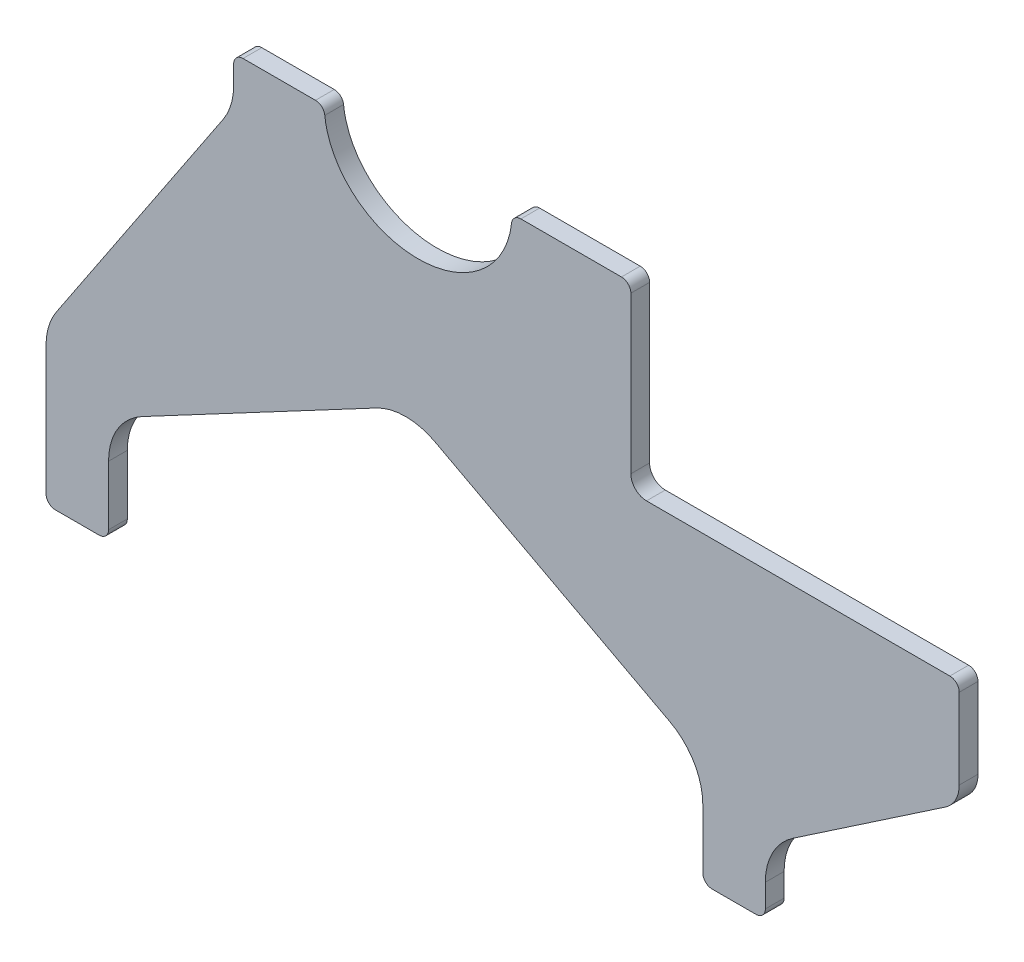
from build123d import *

# Parameters (mm, degrees)
EXTRUDE1_DEPTH = 6


with BuildPart() as part:
    # Sketch1 → Extrude1 (new body)
    with BuildSketch(Plane.XY):
        with BuildLine():
            Line((-9.389431256, -4.992449157), (-84.389431256, -44.870656531))
            ThreePointArc((-84.389431256, -44.870656531), (-92.143346014, -52.22884689), (-95, -62.529608388))
            Line((-95, -62.529608388), (-95, -81.512396008))
            ThreePointArc((-95, -81.512396008), (-95.878679656, -83.633716351), (-98, -84.512396008))
            Line((-98, -84.512396008), (-112, -84.512396008))
            ThreePointArc((-112, -84.512396008), (-114.121320344, -83.633716351), (-115, -81.512396008))
            Line((-115, -81.512396008), (-115, -40.567908762))
            ThreePointArc((-115, -40.567908762), (-114.14184053, -34.772225789), (-111.641005887, -29.473904838))
            Line((-111.641005887, -29.473904838), (-58.358994113, 50.449112822))
            ThreePointArc((-58.358994113, 50.449112822), (-55.85815947, 55.747433773), (-55, 61.543116747))
            Line((-55, 61.543116747), (-55, 67.487603992))
            ThreePointArc((-55, 67.487603992), (-54.121320344, 69.608924336), (-52, 70.487603992))
            Line((-52, 70.487603992), (-28.840084091, 70.487603992))
            ThreePointArc((-28.840084091, 70.487603992), (-26.834640517, 69.718791136), (-25.85707081, 67.806401373))
            add(Edge.make_bspline(
                [(-25.85707081, 67.806401373), (-23.204663037, 42.987603992), (4, 42.987603992), (31.204663037, 42.987603992), (33.85707081, 67.806401373)],
                knots=[3.239246064, 3.239246064, 3.239246064, 4.71238898, 4.71238898, 6.185531897, 6.185531897, 6.185531897], degree=2, weights=[1, 0.740776038, 1, 0.740776038, 1]))
            ThreePointArc((33.85707081, 67.806401373), (34.834640517, 69.718791136), (36.840084091, 70.487603992))
            Line((36.840084091, 70.487603992), (69, 70.487603992))
            ThreePointArc((69, 70.487603992), (71.121320344, 69.608924336), (72, 67.487603992))
            Line((72, 67.487603992), (72, 17.487603992))
            ThreePointArc((72, 17.487603992), (73.464466094, 13.952070086), (77, 12.487603992))
            Line((77, 12.487603992), (174, 12.487603992))
            ThreePointArc((174, 12.487603992), (176.121320344, 11.608924336), (177, 9.487603992))
            Line((177, 9.487603992), (177, -16.208108765))
            ThreePointArc((177, -16.208108765), (175.834161378, -20.894001715), (172.608481452, -24.48729567))
            Line((172.608481452, -24.48729567), (123.783037097, -57.562596684))
            ThreePointArc((123.783037097, -57.562596684), (117.331677243, -64.749184594), (115, -74.120970494))
            Line((115, -74.120970494), (115, -81.512396008))
            ThreePointArc((115, -81.512396008), (114.121320344, -83.633716351), (112, -84.512396008))
            Line((112, -84.512396008), (98, -84.512396008))
            ThreePointArc((98, -84.512396008), (95.878679656, -83.633716351), (95, -81.512396008))
            Line((95, -81.512396008), (95, -62.529608388))
            ThreePointArc((95, -62.529608388), (92.143346014, -52.22884689), (84.389431256, -44.870656531))
            Line((84.389431256, -44.870656531), (9.389431256, -4.992449157))
            ThreePointArc((9.389431256, -4.992449157), (0, -2.651401014), (-9.389431256, -4.992449157))
        make_face()
    extrude(amount=EXTRUDE1_DEPTH)


solid = part.part
